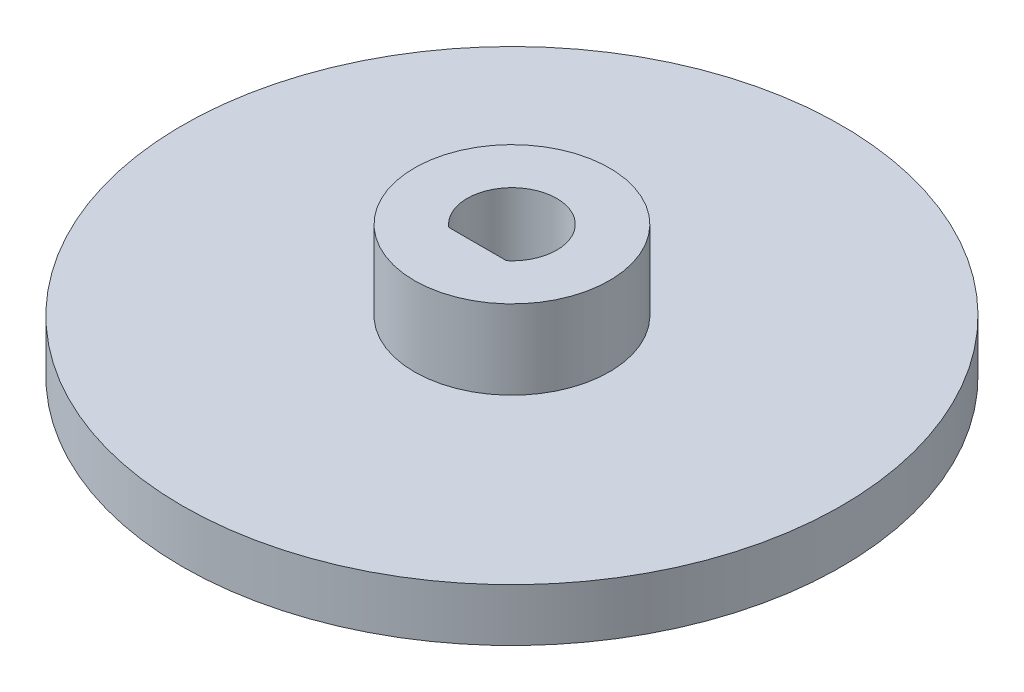
from build123d import *

# Parameters (mm, degrees)
SKETCH1_R           = 12.5
BOSS_EXTRUDE1_DEPTH = 2
SKETCH2_R           = 3.7
BOSS_EXTRUDE2_DEPTH = 3


with BuildPart() as part:
    # Sketch1 → Boss-Extrude1 (new body)
    with BuildSketch(Plane(origin=(0, 0, 0), x_dir=(1, 0, 0), z_dir=(0, 1, 0))):
        Circle(SKETCH1_R)
        with BuildLine():
            Line((1.095445115, -1.3), (-1.095445115, -1.3))
            ThreePointArc((-1.095445115, -1.3), (0, 1.7), (1.095445115, -1.3))
        make_face(mode=Mode.SUBTRACT)
    extrude(amount=BOSS_EXTRUDE1_DEPTH)

    # Sketch2 → Boss-Extrude2 (add)
    with BuildSketch(Plane(origin=(0, 2, 0), x_dir=(1, 0, 0), z_dir=(0, 1, 0))):
        Circle(SKETCH2_R)
        with BuildLine():
            Line((-1.095445115, -1.3), (1.095445115, -1.3))
            ThreePointArc((1.095445115, -1.3), (0, 1.7), (-1.095445115, -1.3))
        make_face(mode=Mode.SUBTRACT)
    extrude(amount=BOSS_EXTRUDE2_DEPTH)


solid = part.part
